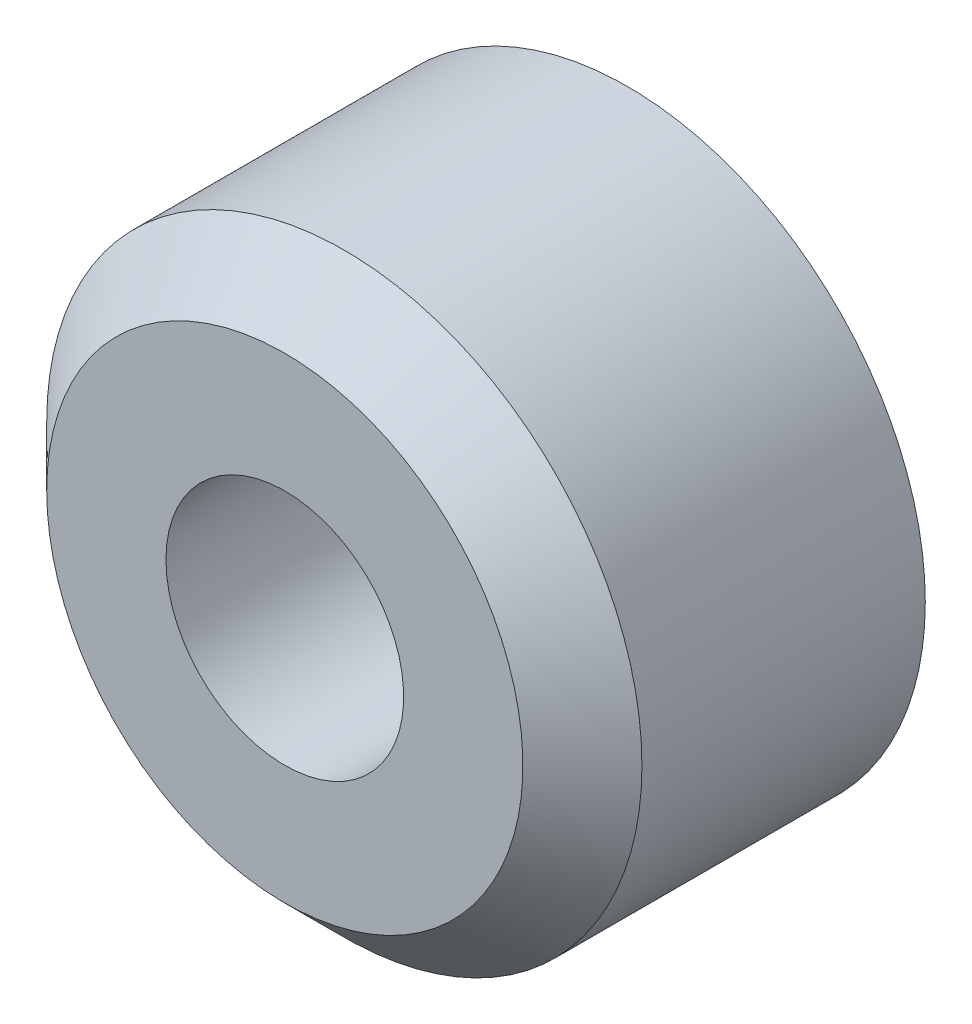
from build123d import *


with BuildPart() as part:
    # Sketch1 → Revolve1 (revolve)
    with BuildSketch(Plane.XZ):
        Polygon((3.96875, 3.77825), (3.175, 4.572), (1.58496, 4.572), (1.58496, 0), (3.96875, 0), align=None)
    revolve(axis=Axis((0, 0, 4.572), (0, 0, -1)))


solid = part.part
